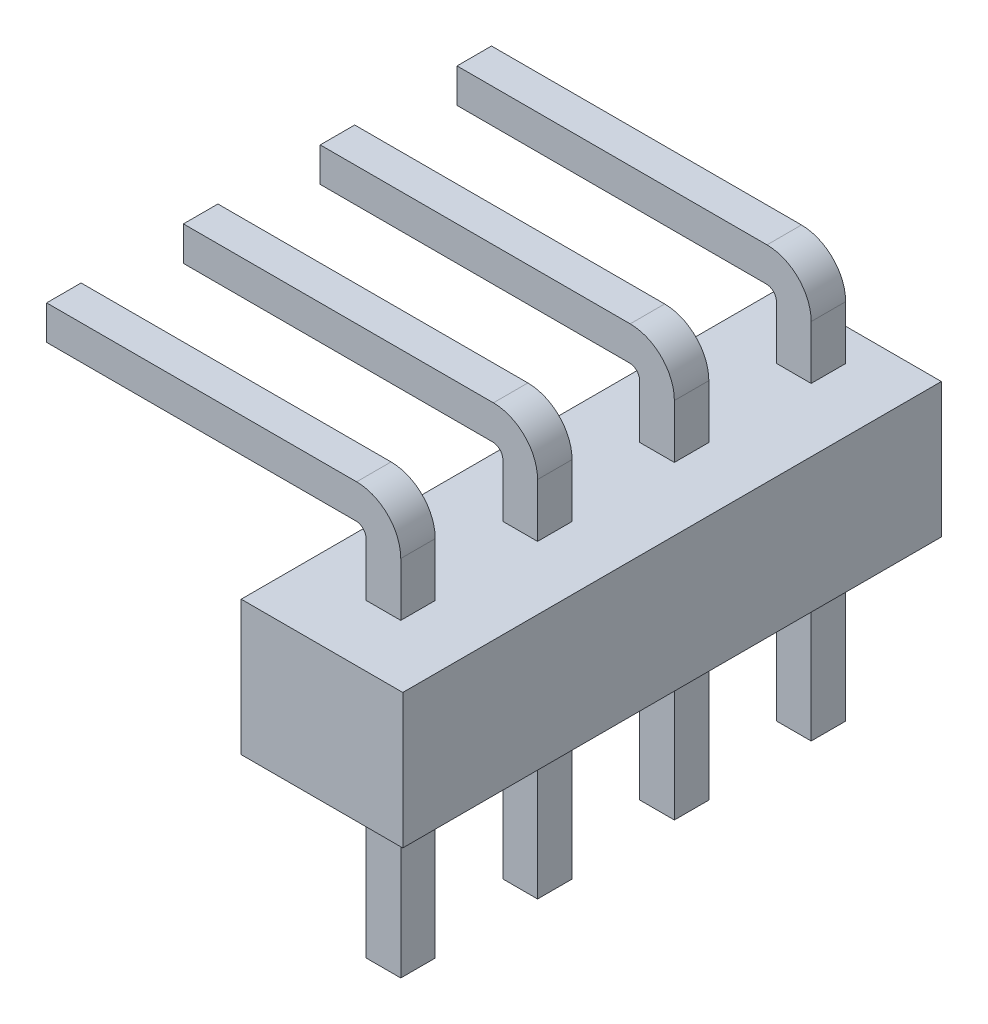
from build123d import *

# Parameters (mm, degrees)
SKETCH1_W       = 3
SKETCH1_H       = 2.5
EXTRUDE1_DEPTH  = 5
SKETCH2_W       = 0.645
SKETCH2_H       = 3.5
EXTRUDE2_DEPTH  = 0.64
LPATTERN1_COUNT = 4
LPATTERN1_PITCH = 2.54
CHAMFER1_SIZE   = 0.25


with BuildPart() as part:
    # Sketch1 → Extrude1 (new body, symmetric)
    with BuildSketch(Plane.XY):
        Rectangle(SKETCH1_W, SKETCH1_H)
    extrude(amount=EXTRUDE1_DEPTH, both=True)

    # Sketch2 → Extrude2 (add)
    with BuildSketch(Plane.XY.offset(3.86)):
        with BuildLine():
            Line((-0.3225, 1.25), (-0.3225, 2.245))
            ThreePointArc((-0.3225, 2.245), (-0.374776878, 2.375), (-0.5025, 2.43261663))
            Line((-0.5025, 2.43261663), (-6.5025, 2.43261663))
            Line((-6.5025, 2.43261663), (-6.5025, 3.06831282))
            Line((-6.5025, 3.06831282), (-0.4975, 3.06831282))
            ThreePointArc((-0.4975, 3.06831282), (0.082527742, 2.826), (0.3225, 2.245))
            Line((0.3225, 2.245), (0.3225, 1.25))
            Line((0.3225, 1.25), (-0.3225, 1.25))
        make_face()
        with Locations((0, -3)):
            Rectangle(SKETCH2_W, SKETCH2_H)
    extrude2 = extrude(amount=-EXTRUDE2_DEPTH)

    # LPattern1: Extrude2 ×4
    with Locations(*[(0, 0, -i * LPATTERN1_PITCH) for i in range(1, LPATTERN1_COUNT)]):
        add(extrude2)

    # Chamfer1
    chamfer1_edges = [part.edges().sort_by_distance(p)[0] for p in [
        (-6.5025, 2.750464725, -4.4),
        (-6.5025, 2.43261663, -4.08),
        (-6.5025, 3.06831282, -4.08),
        (-6.5025, 2.750464725, -3.76),
        (0, -4.75, -4.4),
        (0.3225, -4.75, -4.08),
        (-0.3225, -4.75, -4.08),
        (0, -4.75, -3.76),
        (-6.5025, 2.750464725, 3.22),
        (-6.5025, 2.43261663, 3.54),
        (-6.5025, 3.06831282, 3.54),
        (-6.5025, 2.750464725, 3.86),
        (0, -4.75, 3.22),
        (0.3225, -4.75, 3.54),
        (-0.3225, -4.75, 3.54),
        (0, -4.75, 3.86),
        (-6.5025, 2.750464725, 0.68),
        (-6.5025, 2.43261663, 1),
        (-6.5025, 3.06831282, 1),
        (-6.5025, 2.750464725, 1.32),
        (0, -4.75, 0.68),
        (0.3225, -4.75, 1),
        (-0.3225, -4.75, 1),
        (0, -4.75, 1.32),
        (-6.5025, 2.750464725, -1.86),
        (-6.5025, 2.43261663, -1.54),
        (-6.5025, 3.06831282, -1.54),
        (-6.5025, 2.750464725, -1.22),
        (0, -4.75, -1.86),
        (0.3225, -4.75, -1.54),
        (-0.3225, -4.75, -1.54),
        (0, -4.75, -1.22),
    ]]
    chamfer(chamfer1_edges, length=CHAMFER1_SIZE)


solid = part.part
